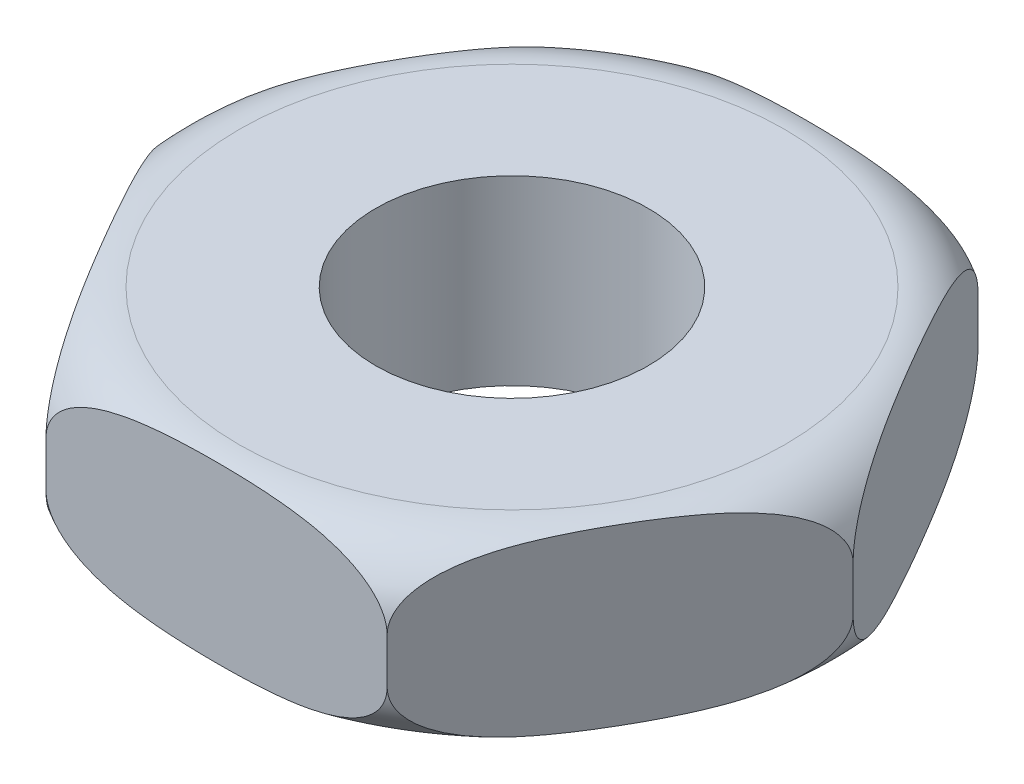
from build123d import *

# Parameters (mm, degrees)
SKETCH1_R           = 6
BOSS_EXTRUDE1_DEPTH = 4


with BuildPart() as part:
    # Sketch1 → Boss-Extrude1 (new body, symmetric)
    with BuildSketch(Plane(origin=(0, 0, 0), x_dir=(1, 0, 0), z_dir=(0, 1, 0))):
        Polygon((15.011106999, 0), (7.505553499, 13), (-7.505553499, 13), (-15.011106999, 0), (-7.505553499, -13), (7.505553499, -13), align=None)
        Circle(SKETCH1_R, mode=Mode.SUBTRACT)
    extrude(amount=BOSS_EXTRUDE1_DEPTH, both=True)

    # Sketch2 → Cut-Revolve1 (revolve, cut)
    with BuildSketch(Plane.XY):
        with BuildLine():
            Line((15.011106999, 1), (15.011106999, 4))
            Line((15.011106999, 4), (12.011106999, 4))
            ThreePointArc((12.011106999, 4), (14.132427342, 3.121320344), (15.011106999, 1))
        make_face()
    cut_revolve1 = revolve(axis=Axis((0, 7.294501908, 0), (0, -1, 0)), mode=Mode.SUBTRACT)

    # Mirror1: Cut-Revolve1 across plane
    add(cut_revolve1.mirror(Plane.ZX), mode=Mode.SUBTRACT)


solid = part.part
